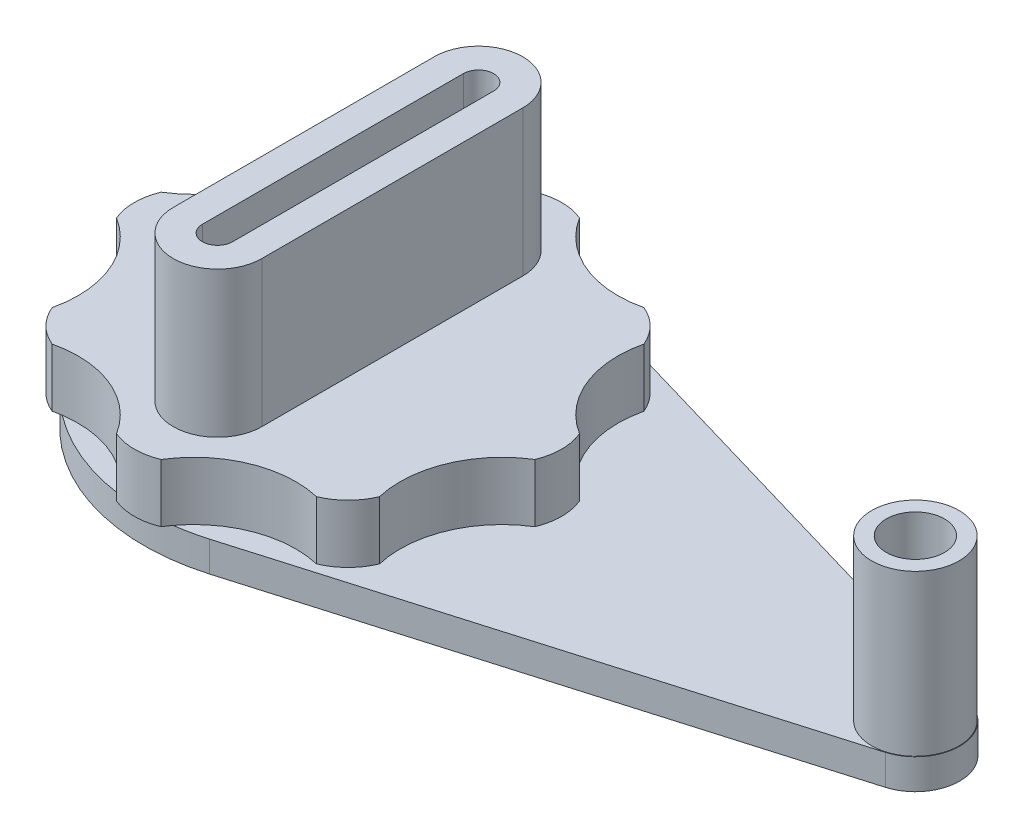
from build123d import *

# Parameters (mm, degrees)
BOSS_EXTRUDE1_DEPTH = 1.651
BOSS_EXTRUDE2_DEPTH = 6.35
BOSS_EXTRUDE3_START = -6.35
BOSS_EXTRUDE3_DEPTH = 22.225
BOSS_EXTRUDE4_START = -1.5875
SKETCH5_R           = 4.7625
BOSS_EXTRUDE4_DEPTH = 19.05
SKETCH6_R           = 3.175
CUT_EXTRUDE1_DEPTH  = 17.4625
SKETCH7_R           = 19.05
CUT_EXTRUDE3_DEPTH  = 6.35
SKETCH8_R           = 13.335
SKETCH8_R_2         = 9.525
BOSS_EXTRUDE5_DEPTH = 7.9375
SKETCH9_R           = 4.7625
BOSS_EXTRUDE6_DEPTH = 12.7
FILLET3_R           = 3.81


with BuildPart() as part:
    # Sketch1 → Boss-Extrude1 (new body, symmetric)
    with BuildSketch(Plane(origin=(0, 0, 0), x_dir=(1, 0, 0), z_dir=(0, 1, 0))):
        with BuildLine():
            Line((6.252207392, 21.327459477), (63.206622177, 4.631105486))
            ThreePointArc((63.206622177, 4.631105486), (66.675, 0), (63.206622177, -4.631105486))
            Line((63.206622177, -4.631105486), (6.252207392, -21.327459477))
            ThreePointArc((6.252207392, -21.327459477), (-22.225, 0), (6.252207392, 21.327459477))
        make_face()
    extrude(amount=BOSS_EXTRUDE1_DEPTH, both=True)

    # Sketch2 → Boss-Extrude2 (add)
    with BuildSketch(Plane(origin=(0, 1.651, 0), x_dir=(1, 0, 0), z_dir=(0, 1, 0))):
        with BuildLine():
            ThreePointArc((-17.844535667, 14.407940431), (-16.468028697, 16.468028697), (-14.407940431, 17.844535667))
            ThreePointArc((-14.407940431, 17.844535667), (-7.620469402, 18.397440581), (-2.430039796, 22.80594456))
            ThreePointArc((-2.430039796, 22.80594456), (0, 23.289309528), (2.430039796, 22.80594456))
            ThreePointArc((2.430039796, 22.80594456), (7.620469402, 18.397440581), (14.407940431, 17.844535667))
            ThreePointArc((14.407940431, 17.844535667), (16.468028697, 16.468028697), (17.844535667, 14.407940431))
            ThreePointArc((17.844535667, 14.407940431), (18.397440581, 7.620469402), (22.80594456, 2.430039796))
            ThreePointArc((22.80594456, 2.430039796), (23.289309528, 0), (22.80594456, -2.430039796))
            ThreePointArc((22.80594456, -2.430039796), (18.397440581, -7.620469402), (17.844535667, -14.407940431))
            ThreePointArc((17.844535667, -14.407940431), (16.468028697, -16.468028697), (14.407940431, -17.844535667))
            ThreePointArc((14.407940431, -17.844535667), (7.620469402, -18.397440581), (2.430039796, -22.80594456))
            ThreePointArc((2.430039796, -22.80594456), (0, -23.289309528), (-2.430039796, -22.80594456))
            ThreePointArc((-2.430039796, -22.80594456), (-7.620469402, -18.397440581), (-14.407940431, -17.844535667))
            ThreePointArc((-14.407940431, -17.844535667), (-16.468028697, -16.468028697), (-17.844535667, -14.407940431))
            ThreePointArc((-17.844535667, -14.407940431), (-18.397440581, -7.620469402), (-22.80594456, -2.430039796))
            ThreePointArc((-22.80594456, -2.430039796), (-23.289309528, 0), (-22.80594456, 2.430039796))
            ThreePointArc((-22.80594456, 2.430039796), (-18.397440581, 7.620469402), (-17.844535667, 14.407940431))
        make_face()
    extrude(amount=BOSS_EXTRUDE2_DEPTH)

    # Sketch4 → Boss-Extrude3 (add)
    with BuildSketch(Plane(origin=(0, 8.001, 0), x_dir=(1, 0, 0), z_dir=(0, 1, 0)).offset(BOSS_EXTRUDE3_START)):
        with BuildLine():
            Line((-4.826, -14.224), (-4.826, 14.224))
            ThreePointArc((-4.826, 14.224), (0, 19.05), (4.826, 14.224))
            Line((4.826, 14.224), (4.826, -14.224))
            ThreePointArc((4.826, -14.224), (0, -19.05), (-4.826, -14.224))
        make_face()
        with BuildLine():
            Line((-1.651, -14.224), (-1.651, 14.224))
            ThreePointArc((-1.651, 14.224), (0, 15.875), (1.651, 14.224))
            Line((1.651, 14.224), (1.651, -14.224))
            ThreePointArc((1.651, -14.224), (0, -15.875), (-1.651, -14.224))
        make_face(mode=Mode.SUBTRACT)
    extrude(amount=BOSS_EXTRUDE3_DEPTH)

    # Sketch5 → Boss-Extrude4 (add)
    with BuildSketch(Plane(origin=(0, 1.651, 0), x_dir=(1, 0, 0), z_dir=(0, 1, 0)).offset(BOSS_EXTRUDE4_START)):
        with Locations((61.849, 0)):
            Circle(SKETCH5_R)
    extrude(amount=BOSS_EXTRUDE4_DEPTH)

    # Sketch6 → Cut-Extrude1 (cut)
    with BuildSketch(Plane(origin=(0, 19.1135, 0), x_dir=(1, 0, 0), z_dir=(0, 1, 0))):
        with Locations((61.849, 0)):
            Circle(SKETCH6_R)
    extrude(amount=-CUT_EXTRUDE1_DEPTH, mode=Mode.SUBTRACT)

    # Sketch7 → Cut-Extrude3 (cut)
    with BuildSketch(Plane(origin=(0, -1.651, 0), x_dir=(1, 0, 0), z_dir=(0, 1, 0))):
        Circle(SKETCH7_R)
    extrude(amount=CUT_EXTRUDE3_DEPTH, mode=Mode.SUBTRACT)

    # Sketch8 → Boss-Extrude5 (add)
    with BuildSketch(Plane.XZ.offset(-4.699)):
        Circle(SKETCH8_R)
        Circle(SKETCH8_R_2, mode=Mode.SUBTRACT)
    extrude(amount=BOSS_EXTRUDE5_DEPTH)

    # Sketch9 → Boss-Extrude6 (add)
    with BuildSketch(Plane.XZ.offset(-4.699)):
        Circle(SKETCH9_R)
    extrude(amount=BOSS_EXTRUDE6_DEPTH)

    # Fillet3
    fillet3_edges = [part.edges().sort_by_distance(p)[0] for p in [
        (-4.7625, -8.001, 0),
    ]]
    fillet(fillet3_edges, radius=FILLET3_R)


solid = part.part
